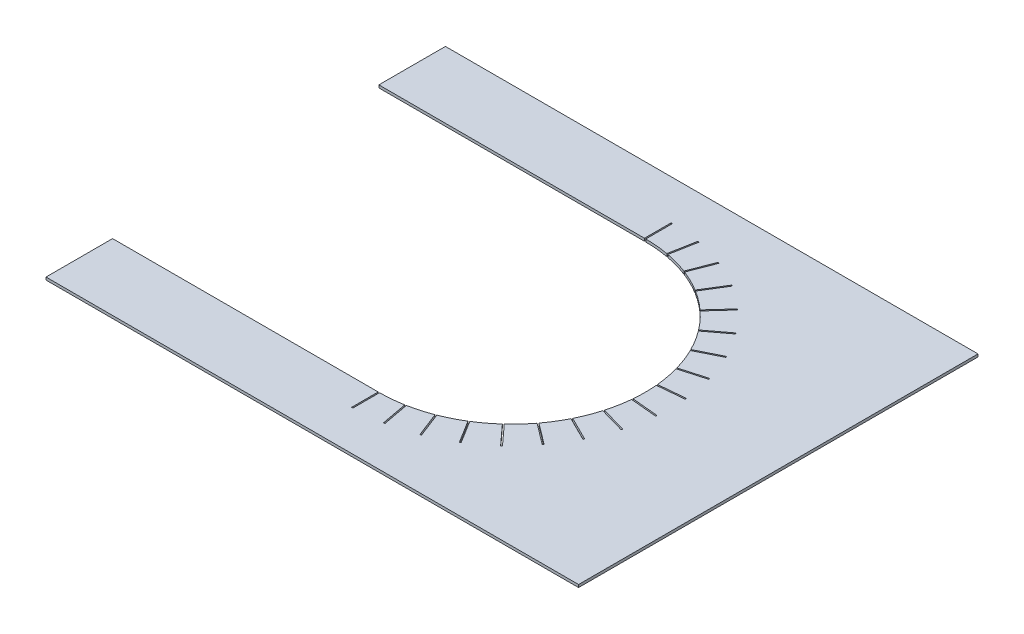
from build123d import *

# Parameters (mm, degrees)
AUFSATZ_LINEAR_AUSTRAGEN1_DEPTH      = 1
SKIZZE2_W                            = 0.5
SKIZZE2_H                            = 15
SCHNITT_LINEAR_AUSTRAGEN_D_NN4_DEPTH = 2
KREISMUSTER12_COUNT                  = 18
KREISMUSTER12_ANGLE                  = 180


with BuildPart() as part:
    # Skizze1 → Aufsatz-Linear austragen1 (new body)
    with BuildSketch(Plane(origin=(0, 0, 0), x_dir=(1, 0, 0), z_dir=(0, 1, 0))):
        with BuildLine():
            Line((0, 50), (-100, 50))
            Line((-100, 50), (-100, 75))
            Line((-100, 75), (100, 75))
            Line((100, 75), (100, -75))
            Line((100, -75), (-100, -75))
            Line((-100, -75), (-100, -50))
            Line((-100, -50), (0, -50))
            ThreePointArc((0, -50), (50, 0), (0, 50))
        make_face()
    extrude(amount=AUFSATZ_LINEAR_AUSTRAGEN1_DEPTH)

    # Skizze2 → Schnitt-Linear-Austragen-Dünn4 (cut)
    with BuildSketch(Plane(origin=(0, 0, 0), x_dir=(1, 0, 0), z_dir=(0, 1, 0))):
        with Locations((0, 52.5)):
            Rectangle(SKIZZE2_W, SKIZZE2_H)
    schnitt_linear_austragen_d_nn4 = extrude(amount=SCHNITT_LINEAR_AUSTRAGEN_D_NN4_DEPTH, mode=Mode.SUBTRACT)

    # Kreismuster12: Schnitt-Linear-Austragen-Dünn4 ×18 about axis
    kreismuster12_axis = Axis((0, 0, 0), (0, -1, 0))
    for i in range(1, KREISMUSTER12_COUNT):
        add(schnitt_linear_austragen_d_nn4.rotate(kreismuster12_axis, i * KREISMUSTER12_ANGLE / (KREISMUSTER12_COUNT - 1)), mode=Mode.SUBTRACT)


solid = part.part
